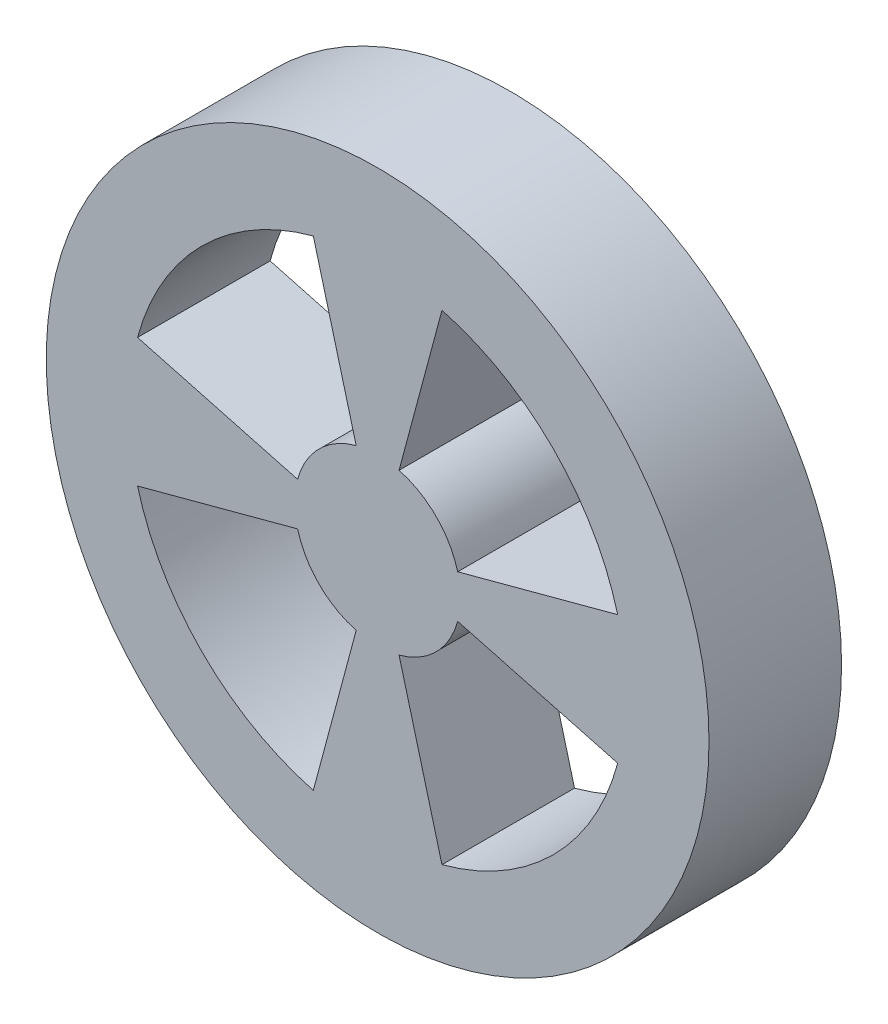
from build123d import *

# Parameters (mm, degrees)
SKETCH1_R           = 1
BOSS_EXTRUDE1_DEPTH = 0.4


with BuildPart() as part:
    # Sketch1 → Boss-Extrude1 (new body)
    with BuildSketch(Plane.XY):
        Circle(SKETCH1_R)
        with BuildLine():
            Line((-0.72444437, 0.194114284), (-0.241481457, 0.064704761))
            ThreePointArc((-0.241481457, 0.064704761), (-0.176776695, 0.176776695), (-0.064704761, 0.241481457))
            Line((-0.064704761, 0.241481457), (-0.194114284, 0.72444437))
            ThreePointArc((-0.194114284, 0.72444437), (-0.530330086, 0.530330086), (-0.72444437, 0.194114284))
        make_face(mode=Mode.SUBTRACT)
        with BuildLine():
            Line((0.194114284, 0.72444437), (0.064704761, 0.241481457))
            ThreePointArc((0.064704761, 0.241481457), (0.176776695, 0.176776695), (0.241481457, 0.064704761))
            Line((0.241481457, 0.064704761), (0.72444437, 0.194114284))
            ThreePointArc((0.72444437, 0.194114284), (0.530330086, 0.530330086), (0.194114284, 0.72444437))
        make_face(mode=Mode.SUBTRACT)
        with BuildLine():
            Line((0.194114284, -0.72444437), (0.064704761, -0.241481457))
            ThreePointArc((0.064704761, -0.241481457), (0.176776695, -0.176776695), (0.241481457, -0.064704761))
            Line((0.241481457, -0.064704761), (0.72444437, -0.194114284))
            ThreePointArc((0.72444437, -0.194114284), (0.530330086, -0.530330086), (0.194114284, -0.72444437))
        make_face(mode=Mode.SUBTRACT)
        with BuildLine():
            Line((-0.194114284, -0.72444437), (-0.064704761, -0.241481457))
            ThreePointArc((-0.064704761, -0.241481457), (-0.176776695, -0.176776695), (-0.241481457, -0.064704761))
            Line((-0.241481457, -0.064704761), (-0.72444437, -0.194114284))
            ThreePointArc((-0.72444437, -0.194114284), (-0.530330086, -0.530330086), (-0.194114284, -0.72444437))
        make_face(mode=Mode.SUBTRACT)
    extrude(amount=BOSS_EXTRUDE1_DEPTH)


solid = part.part
